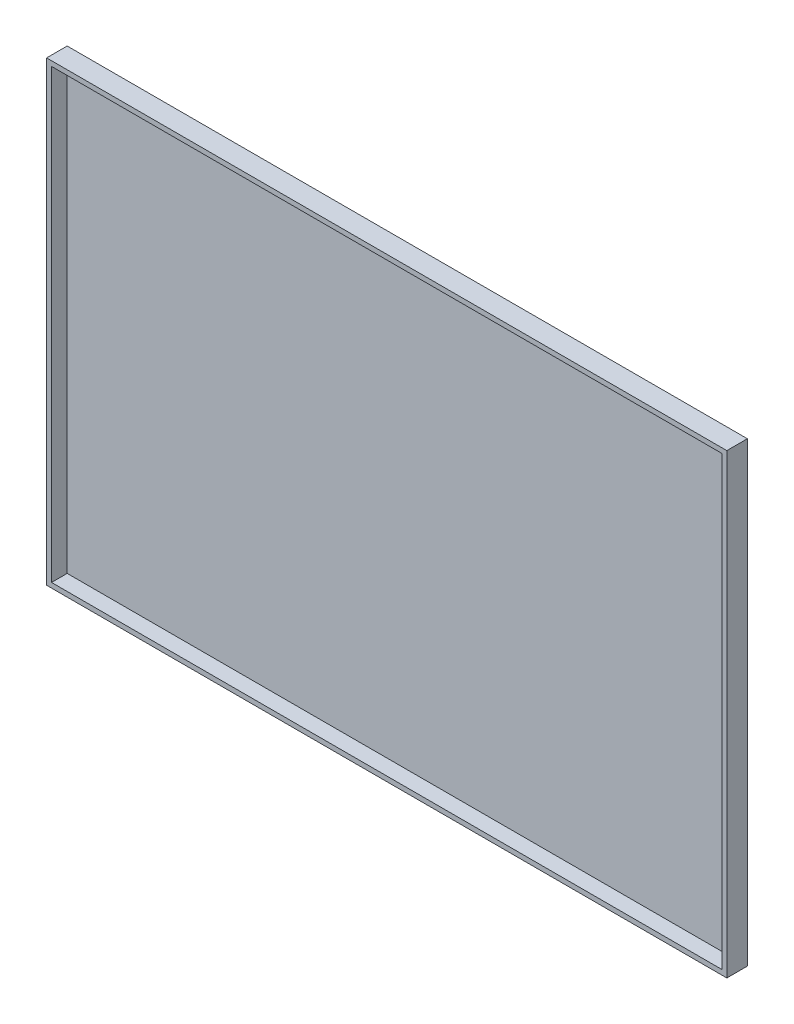
from build123d import *

# Parameters (mm, degrees)
ESQUISSE1_W   = 3000
ESQUISSE1_H   = 2000
BOTTOM_DEPTH  = 22
ESQUISSE2_W   = 3044
ESQUISSE2_H   = 2044
ESQUISSE2_W_2 = 3000
ESQUISSE2_H_2 = 2000
BORDER_DEPTH  = 92


with BuildPart() as part:
    # Esquisse1 → Bottom (new body)
    with BuildSketch(Plane.XY):
        Rectangle(ESQUISSE1_W, ESQUISSE1_H)
    extrude(amount=BOTTOM_DEPTH)


with BuildPart() as body_2:
    # Esquisse2 → Border (new body)
    with BuildSketch(Plane(origin=(0, 0, 0), x_dir=(-1, 0, 0), z_dir=(0, 0, -1))):
        Rectangle(ESQUISSE2_W, ESQUISSE2_H)
        Rectangle(ESQUISSE2_W_2, ESQUISSE2_H_2, mode=Mode.SUBTRACT)
    extrude(amount=-BORDER_DEPTH)


solid = Compound([part.part, body_2.part])
